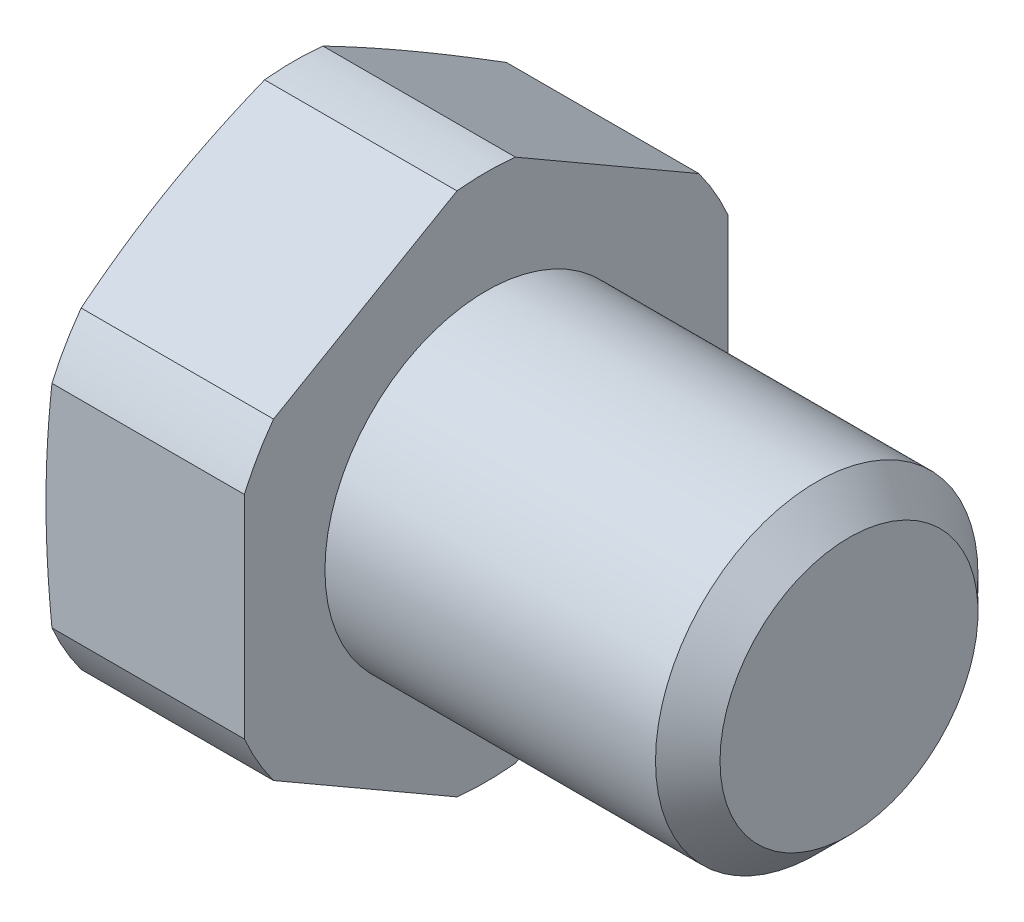
from build123d import *

# Parameters (mm, degrees)
SKETCH_2_OUTSIDE_W  = 37.488
SKETCH_2_OUTSIDE_H  = 37.488
CUT_EXTRUDE_1_DEPTH = 28


with BuildPart() as part:
    # Эскиз1 → Повернуть1 (revolve)
    with BuildSketch(Plane.XY):
        Polygon((-10, 0), (-10, 11.4), (-9.544486373, 13.1), (0, 13.1), (0, 8), (16.4, 8), (18, 6.4), (18, 0), align=None)
    revolve(axis=Axis((-1000, 0, 0), (1, 0, 0)))

    # Эскиз2 outside → Вырез-Вытянуть1 (cut)
    with BuildSketch(Plane.ZY.offset(10)):
        Rectangle(SKETCH_2_OUTSIDE_W, SKETCH_2_OUTSIDE_H)
        Polygon((0, 13.856406461), (-12, 6.92820323), (-12, -6.92820323), (0, -13.856406461), (12, -6.92820323), (12, 6.92820323), align=None, mode=Mode.SUBTRACT)
    extrude(amount=-CUT_EXTRUDE_1_DEPTH, mode=Mode.SUBTRACT)


solid = part.part
